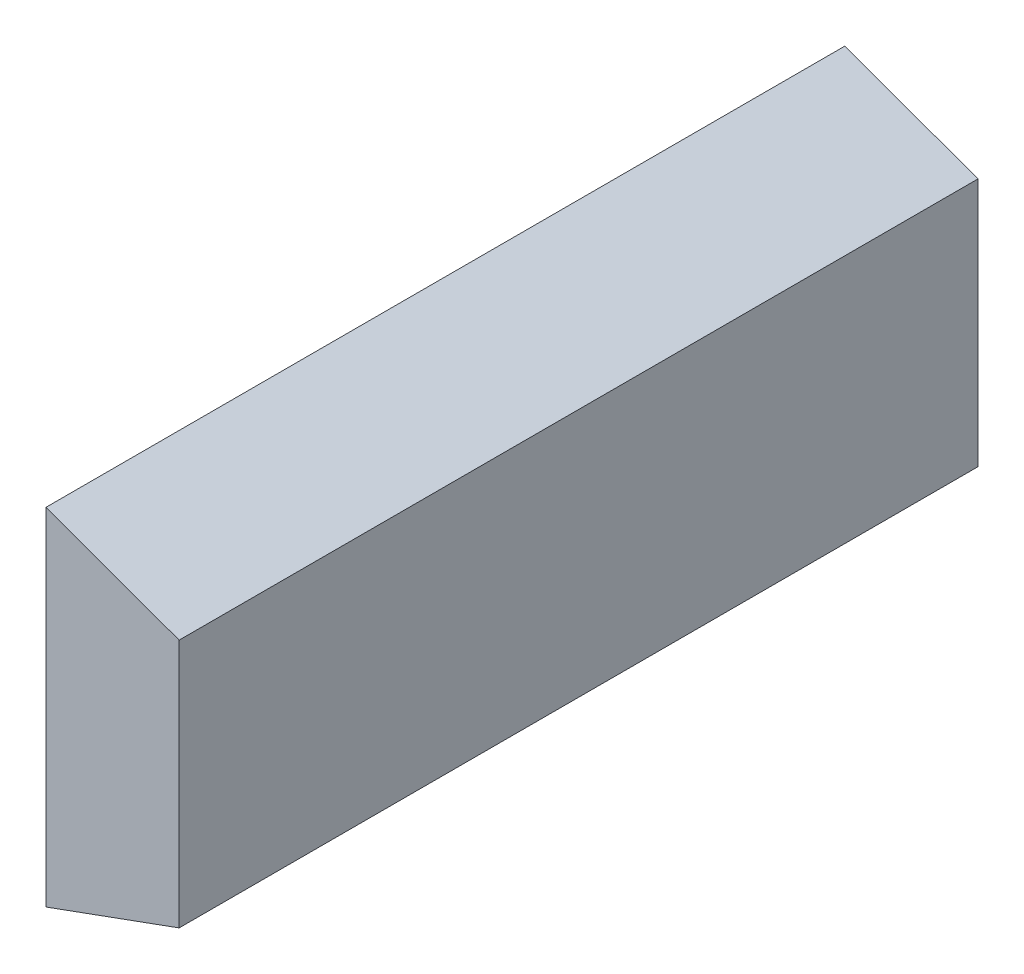
from build123d import *

# Parameters (mm, degrees)
BOSS_EXTRUDE1_DEPTH = 15


with BuildPart() as part:
    # Sketch1 → Boss-Extrude1 (new body)
    with BuildSketch(Plane.XY):
        Polygon((61.753708947, -18.154902685), (61.753708947, -24.654902685), (64.253708947, -23.7449771), (64.253708947, -19.064828271), align=None)
    extrude(amount=-BOSS_EXTRUDE1_DEPTH)


solid = part.part
